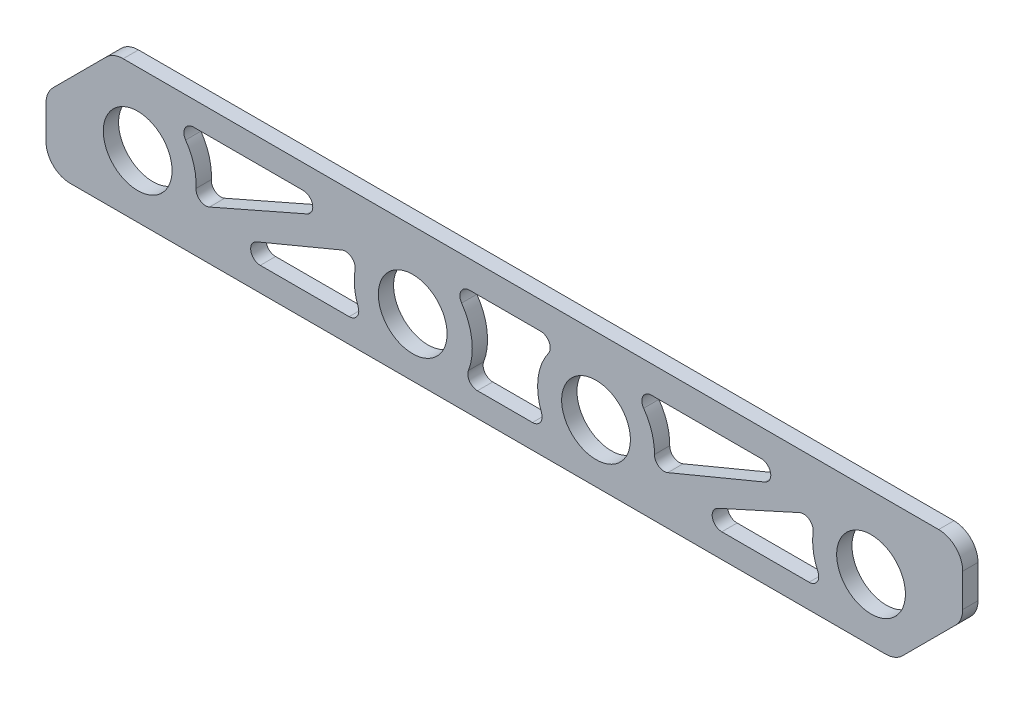
from build123d import *

# Parameters (mm, degrees)
SKETCH1_R           = 14.2875
BOSS_EXTRUDE1_DEPTH = 6.35
FILLET1_R           = 10
FILLET2_R           = 4
FILLET3_R           = 4


with BuildPart() as part:
    # Sketch1 → Boss-Extrude1 (new body)
    with BuildSketch(Plane.XY):
        Polygon((0, 27.94), (0, 0), (353.06, 0), (363.06, 10), (381, 27.94), (381, 55.88), (27.94, 55.88), align=None)
        with Locations((38.1, 25.7175)):
            Circle(SKETCH1_R, mode=Mode.SUBTRACT)
        with BuildLine():
            Line((132.645867363, 10), (69.059384531, 10))
            Line((69.059384531, 10), (131.13384809, 35.861727885))
            ThreePointArc((131.13384809, 35.861727885), (128.153903852, 22.712439471), (132.645867363, 10))
        make_face(mode=Mode.SUBTRACT)
        with Locations((152.4, 24.13)):
            Circle(SKETCH1_R, mode=Mode.SUBTRACT)
        with Locations((228.6, 24.13)):
            Circle(SKETCH1_R, mode=Mode.SUBTRACT)
        with BuildLine():
            Line((208.845867363, 10), (172.736964373, 10))
            ThreePointArc((172.736964373, 10), (176.759470296, 28.58704238), (166.416173693, 44.54557971))
            Line((166.416173693, 44.54557971), (215.443755804, 44.54557971))
            ThreePointArc((215.443755804, 44.54557971), (204.743711621, 28.686331972), (208.845867363, 10))
        make_face(mode=Mode.SUBTRACT)
        with BuildLine():
            Line((324.38398396, 10), (262.377905487, 10))
            Line((262.377905487, 10), (321.240476687, 36.706026112))
            ThreePointArc((321.240476687, 36.706026112), (318.779024724, 22.878273345), (324.38398396, 10))
        make_face(mode=Mode.SUBTRACT)
        with Locations((342.9, 25.7175)):
            Circle(SKETCH1_R, mode=Mode.SUBTRACT)
        with BuildLine():
            ThreePointArc((60.896352165, 17.338419846), (61.203129855, 33.209365398), (51.640910235, 45.88))
            Line((51.640910235, 45.88), (125.940457816, 45.88))
            Line((125.940457816, 45.88), (60.896352165, 17.338419846))
        make_face(mode=Mode.SUBTRACT)
        with BuildLine():
            ThreePointArc((251.928870535, 17.373783913), (251.345714342, 32.645581912), (241.756244196, 44.54557971))
            Line((241.756244196, 44.54557971), (317.257409157, 44.54557971))
            Line((317.257409157, 44.54557971), (251.928870535, 17.373783913))
        make_face(mode=Mode.SUBTRACT)
    extrude(amount=BOSS_EXTRUDE1_DEPTH)

    # Fillet1
    fillet1_edges = [part.edges().sort_by_distance(p)[0] for p in [
        (0, 0, 3.175),
        (0, 27.94, 3.175),
        (27.94, 55.88, 3.175),
        (381, 55.88, 3.175),
        (381, 27.94, 3.175),
        (353.06, 0, 3.175),
    ]]
    fillet(fillet1_edges, radius=FILLET1_R)

    # Fillet2
    fillet2_edges = [part.edges().sort_by_distance(p)[0] for p in [
        (208.845867363, 10, 3.175),
        (215.443755804, 44.54557971, 3.175),
        (166.416173693, 44.54557971, 3.175),
        (172.736964373, 10, 3.175),
        (69.059384531, 10, 3.175),
        (131.13384809, 35.861727885, 3.175),
        (125.940457816, 45.88, 3.175),
        (60.896352165, 17.338419846, 3.175),
        (251.928870535, 17.373783913, 3.175),
        (317.257409157, 44.54557971, 3.175),
        (321.240476687, 36.706026112, 3.175),
        (262.377905487, 10, 3.175),
    ]]
    fillet(fillet2_edges, radius=FILLET2_R)

    # Fillet3
    fillet3_edges = [part.edges().sort_by_distance(p)[0] for p in [
        (132.645867363, 10, 3.175),
        (51.640910235, 45.88, 3.175),
        (241.756244196, 44.54557971, 3.175),
        (324.38398396, 10, 3.175),
    ]]
    fillet(fillet3_edges, radius=FILLET3_R)


solid = part.part
